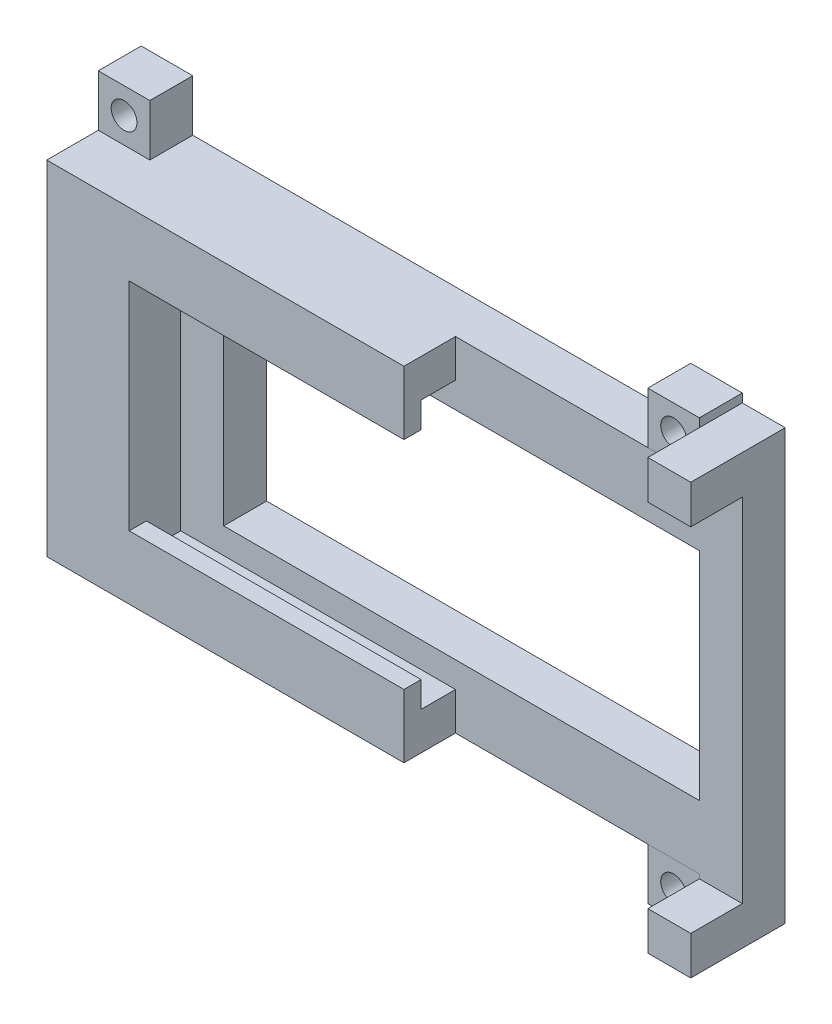
from build123d import *

# Parameters (mm, degrees)
BOSS_EXTRUDE1_DEPTH   = 5
SKETCH4_W             = 5
SKETCH4_H             = 4.5
BOSS_EXTRUDE2_DEPTH   = 6
SKETCH5_W             = 3
SKETCH5_H             = 2
BOSS_EXTRUDE3_DEPTH   = 32
SKETCH6_W             = 6
SKETCH6_H             = 6
BOSS_EXTRUDE4_DEPTH   = 5
BOSS_EXTRUDE4_2_DEPTH = 5
BOSS_EXTRUDE4_3_DEPTH = 5
BOSS_EXTRUDE4_4_DEPTH = 5
SKETCH7_R             = 1.5
CUT_EXTRUDE1_DEPTH    = 6
SKETCH8_W             = 55.4
SKETCH8_H             = 25.2
CUT_EXTRUDE2_DEPTH    = 6


with BuildPart() as part:
    # Sketch1 → Boss-Extrude1 (new body)
    with BuildSketch(Plane(origin=(0, 0, 0), x_dir=(0, 1, 0), z_dir=(0, 0, 1))):
        Polygon((-20, 5), (-20, 75), (20, 75), (20, 5), (25, 5), (25, 0), (-25, 0), (-25, 5), align=None)
    extrude(amount=BOSS_EXTRUDE1_DEPTH)

    # Sketch4 → Boss-Extrude2 (add)
    with BuildSketch(Plane.XY.offset(5)):
        Polygon((-75, 20), (-75, -20), (-33.4, -20), (-33.4, -15.6), (-65.4, -15.6), (-65.4, 15.6), (-33.4, 15.6), (-33.4, 20), align=None)
        with Locations((-2.5, 22.75)):
            Rectangle(SKETCH4_W, SKETCH4_H)
        with Locations((-2.5, -22.75)):
            Rectangle(SKETCH4_W, SKETCH4_H)
    extrude(amount=BOSS_EXTRUDE2_DEPTH)

    # Sketch5 → Boss-Extrude3 (add)
    with BuildSketch(Plane.YZ.offset(-65.4)):
        with Locations((-14.1, 10)):
            Rectangle(SKETCH5_W, SKETCH5_H)
        with Locations((14.1, 10)):
            Rectangle(SKETCH5_W, SKETCH5_H)
    extrude(amount=BOSS_EXTRUDE3_DEPTH)

    # Sketch8 → Cut-Extrude2 (cut, through all)
    with BuildSketch(Plane.XY.offset(5)):
        with Locations((-32.7, 0)):
            Rectangle(SKETCH8_W, SKETCH8_H)
    extrude(amount=-CUT_EXTRUDE2_DEPTH, mode=Mode.SUBTRACT)


with BuildPart() as body_2:
    # Sketch6 → Boss-Extrude4 (new body)
    with BuildSketch(Plane(origin=(0, 0, 0), x_dir=(1, 0, 0), z_dir=(0, 0, -1))):
        with Locations((-8, 23)):
            Rectangle(SKETCH6_W, SKETCH6_H)
    extrude(amount=-BOSS_EXTRUDE4_DEPTH)


with BuildPart() as body_3:
    # Sketch6 → Boss-Extrude4 2 (new body)
    with BuildSketch(Plane(origin=(0, 0, 0), x_dir=(1, 0, 0), z_dir=(0, 0, -1))):
        with Locations((-72, 23)):
            Rectangle(SKETCH6_W, SKETCH6_H)
    extrude(amount=-BOSS_EXTRUDE4_2_DEPTH)


with BuildPart() as body_4:
    # Sketch6 → Boss-Extrude4 3 (new body)
    with BuildSketch(Plane(origin=(0, 0, 0), x_dir=(1, 0, 0), z_dir=(0, 0, -1))):
        with Locations((-8, -23)):
            Rectangle(SKETCH6_W, SKETCH6_H)
    extrude(amount=-BOSS_EXTRUDE4_3_DEPTH)


with BuildPart() as body_5:
    # Sketch6 → Boss-Extrude4 4 (new body)
    with BuildSketch(Plane(origin=(0, 0, 0), x_dir=(1, 0, 0), z_dir=(0, 0, -1))):
        with Locations((-72, -23)):
            Rectangle(SKETCH6_W, SKETCH6_H)
    extrude(amount=-BOSS_EXTRUDE4_4_DEPTH)


with BuildPart() as cut_extrude1_tool:
    # Sketch7 → Cut-Extrude1 (new body, through all)
    with BuildSketch(Plane.XY.offset(5)):
        with Locations((-8, -23)):
            Circle(SKETCH7_R)
        with Locations((-72, -23)):
            Circle(SKETCH7_R)
        with Locations((-8, 23)):
            Circle(SKETCH7_R)
        with Locations((-72, 23)):
            Circle(SKETCH7_R)
    extrude(amount=-CUT_EXTRUDE1_DEPTH)


with BuildPart() as body_2_1:
    add(body_2.part)

    # Cut-Extrude1: cut by cut_extrude1_tool
    add(cut_extrude1_tool.part, mode=Mode.SUBTRACT)


with BuildPart() as body_3_1:
    add(body_3.part)

    # Cut-Extrude1: cut by cut_extrude1_tool
    add(cut_extrude1_tool.part, mode=Mode.SUBTRACT)


with BuildPart() as body_4_1:
    add(body_4.part)

    # Cut-Extrude1: cut by cut_extrude1_tool
    add(cut_extrude1_tool.part, mode=Mode.SUBTRACT)


with BuildPart() as body_5_1:
    add(body_5.part)

    # Cut-Extrude1: cut by cut_extrude1_tool
    add(cut_extrude1_tool.part, mode=Mode.SUBTRACT)


solid = Compound([part.part, body_2_1.part, body_3_1.part, body_4_1.part, body_5_1.part])
